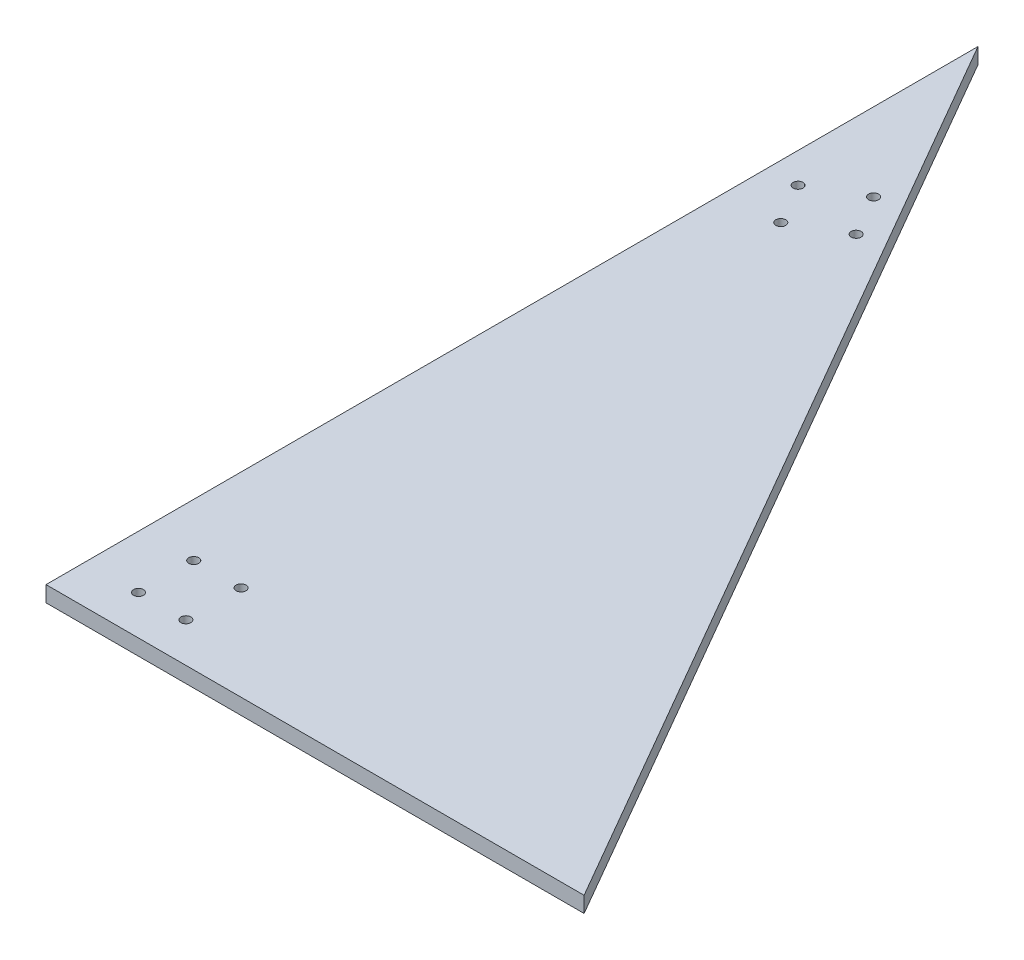
from build123d import *

# Parameters (mm, degrees)
BOSS_EXTRUDE1_DEPTH          = 6.35
F_4_0_4_DIAMETER_HOLE1_D     = 4
F_4_0_4_DIAMETER_HOLE1_DEPTH = 10
F_4_0_4_DIAMETER_HOLE1_TIP   = 1.201721238
F_4_0_4_DIAMETER_HOLE2_D     = 4
F_4_0_4_DIAMETER_HOLE2_DEPTH = 10
F_4_0_4_DIAMETER_HOLE2_TIP   = 1.201721238


with BuildPart() as part:
    # Sketch1 → Boss-Extrude1 (new body)
    with BuildSketch(Plane(origin=(0, 0, 0), x_dir=(1, 0, 0), z_dir=(0, 1, 0))):
        Polygon((0, 0), (216.51, 0), (0, 375), align=None)
    extrude(amount=BOSS_EXTRUDE1_DEPTH)

    # Ø4.0 (4) Diameter Hole1
    with Locations(Plane(origin=(31.757248956, 6.35, -326.345678088), x_dir=(0.50000632, 0, 0.866021755), z_dir=(0, 1, 0))):
        with Locations((21.272379971, -34.925), (40.322379971, -12.7), (244.423337674, -153.137564848), (273.195791575, -147.752490889)):
            Hole(F_4_0_4_DIAMETER_HOLE1_D / 2, depth=F_4_0_4_DIAMETER_HOLE1_DEPTH)
            with Locations((0, 0, -(F_4_0_4_DIAMETER_HOLE1_DEPTH + F_4_0_4_DIAMETER_HOLE1_TIP / 2))):  # 118° drill point
                Cone(0, F_4_0_4_DIAMETER_HOLE1_D / 2, F_4_0_4_DIAMETER_HOLE1_TIP, mode=Mode.SUBTRACT)

    # Ø4.0 (4) Diameter Hole2
    with Locations(Plane(origin=(31.757248956, 0, -326.345678088), x_dir=(-0.50000632, 0, -0.866021755), z_dir=(0, -1, 0))):
        with Locations((-21.272379971, -12.7), (-40.322379971, -34.925), (-253.948458076, -136.639850421), (-263.670671173, -164.250205317)):
            Hole(F_4_0_4_DIAMETER_HOLE2_D / 2, depth=F_4_0_4_DIAMETER_HOLE2_DEPTH)
            with Locations((0, 0, -(F_4_0_4_DIAMETER_HOLE2_DEPTH + F_4_0_4_DIAMETER_HOLE2_TIP / 2))):  # 118° drill point
                Cone(0, F_4_0_4_DIAMETER_HOLE2_D / 2, F_4_0_4_DIAMETER_HOLE2_TIP, mode=Mode.SUBTRACT)


solid = part.part
